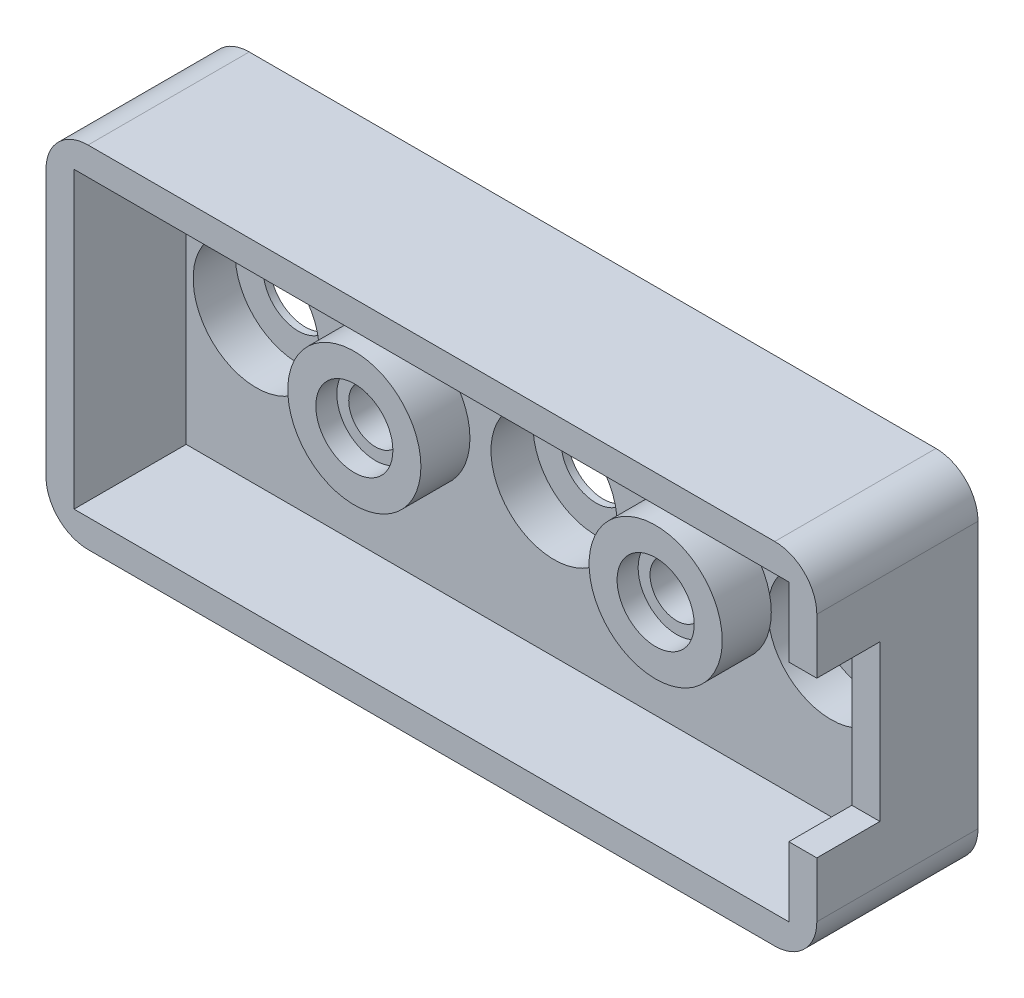
from build123d import *

# Parameters (mm, degrees)
CROQUIS1_W                   = 55
CROQUIS1_H                   = 25
CROQUIS1_R                   = 2.75
SALIENTE_EXTRUIR1_DEPTH      = 2
SALIENTE_EXTRUIR1_DEPTH_BACK = 1.5
CROQUIS2_R                   = 4.75
CROQUIS2_R_2                 = 2.75
SALIENTE_EXTRUIR2_DEPTH      = 3.5
CROQUIS3_W                   = 55
CROQUIS3_H                   = 25
CROQUIS3_W_2                 = 51
CROQUIS3_H_2                 = 21
SALIENTE_EXTRUIR3_DEPTH      = 8
REDONDEO1_R                  = 3
CROQUIS5_W                   = 2
CROQUIS5_H                   = 11.102083366
CORTAR_EXTRUIR1_DEPTH        = 6
CROQUIS8_R                   = 4.5
CORTAR_EXTRUIR4_DEPTH        = 3
CROQUIS11_R                  = 2.75
SALIENTE_EXTRUIR5_DEPTH      = 5.5
CROQUIS12_R                  = 1.9
CORTAR_EXTRUIR11_DEPTH       = 9
CORTAR_EXTRUIR11_DEPTH_BACK  = 4.5
CROQUIS13_R                  = 2.5
CORTAR_EXTRUIR12_DEPTH       = 4.5
CROQUIS14_W                  = 1.5
CROQUIS14_H                  = 11.102083366
SALIENTE_EXTRUIR6_DEPTH      = 2


with BuildPart() as part:
    # Croquis1 → Saliente-Extruir1 (new body, two sides)
    with BuildSketch(Plane.XY) as saliente_extruir1_sk:
        Rectangle(CROQUIS1_W, CROQUIS1_H)
        with Locations((-10, 0)):
            Circle(CROQUIS1_R, mode=Mode.SUBTRACT)
        with Locations((11.5, 0)):
            Circle(CROQUIS1_R, mode=Mode.SUBTRACT)
    extrude(amount=SALIENTE_EXTRUIR1_DEPTH)
    extrude(saliente_extruir1_sk.sketch, amount=-SALIENTE_EXTRUIR1_DEPTH_BACK)

    # Croquis2 → Saliente-Extruir2 (add)
    with BuildSketch(Plane.XY.offset(2)):
        with Locations((-10, 0)):
            Circle(CROQUIS2_R)
        with Locations((-10, 0)):
            Circle(CROQUIS2_R_2, mode=Mode.SUBTRACT)
        with Locations((11.5, 0)):
            Circle(CROQUIS2_R)
        with Locations((11.5, 0)):
            Circle(CROQUIS2_R_2, mode=Mode.SUBTRACT)
    extrude(amount=SALIENTE_EXTRUIR2_DEPTH)

    # Croquis3 → Saliente-Extruir3 (add)
    with BuildSketch(Plane.XY.offset(2)):
        Rectangle(CROQUIS3_W, CROQUIS3_H)
        Rectangle(CROQUIS3_W_2, CROQUIS3_H_2, mode=Mode.SUBTRACT)
    extrude(amount=SALIENTE_EXTRUIR3_DEPTH)

    # Redondeo1
    redondeo1_edges = [part.edges().sort_by_distance(p)[0] for p in [
        (27.5, -12.5, 4.25),
        (-27.5, -12.5, 4.25),
        (-27.5, 12.5, 4.25),
        (27.5, 12.5, 4.25),
    ]]
    fillet(redondeo1_edges, radius=REDONDEO1_R)

    # Croquis5 → Cortar-Extruir1 (cut)
    with BuildSketch(Plane.XY.offset(10)):
        with Locations((26.5, 0)):
            Rectangle(CROQUIS5_W, CROQUIS5_H)
    extrude(amount=-CORTAR_EXTRUIR1_DEPTH, mode=Mode.SUBTRACT)

    # Croquis8 → Cortar-Extruir4 (cut)
    with BuildSketch(Plane.XY.offset(2)):
        with Locations((0.75, 0)):
            Circle(CROQUIS8_R)
        with Locations((-20.5, 0)):
            Circle(CROQUIS8_R)
        with Locations((20.501890269, 0)):
            Circle(CROQUIS8_R)
    extrude(amount=-CORTAR_EXTRUIR4_DEPTH, mode=Mode.SUBTRACT)

    # Croquis11 → Saliente-Extruir5 (add)
    with BuildSketch(Plane(origin=(0, 0, -1.5), x_dir=(-1, 0, 0), z_dir=(0, 0, -1))):
        with Locations((-11.5, 0)):
            Circle(CROQUIS11_R)
        with Locations((10, 0)):
            Circle(CROQUIS11_R)
    extrude(amount=-SALIENTE_EXTRUIR5_DEPTH)

    # Croquis12 → Cortar-Extruir11 (cut, two sides)
    with BuildSketch(Plane.XY.offset(2)) as cortar_extruir11_sk:
        with Locations((-10, 0)):
            Circle(CROQUIS12_R)
        with Locations((11.5, 0)):
            Circle(CROQUIS12_R)
    extrude(amount=CORTAR_EXTRUIR11_DEPTH, mode=Mode.SUBTRACT)
    extrude(cortar_extruir11_sk.sketch, amount=-CORTAR_EXTRUIR11_DEPTH_BACK, mode=Mode.SUBTRACT)

    # Croquis13 → Cortar-Extruir12 (cut, through all)
    with BuildSketch(Plane.XY.offset(2)):
        with Locations((20.501890269, 0)):
            Circle(CROQUIS13_R)
        with Locations((0.75, 0)):
            Circle(CROQUIS13_R)
        with Locations((-20.5, 0)):
            Circle(CROQUIS13_R)
    extrude(amount=-CORTAR_EXTRUIR12_DEPTH, mode=Mode.SUBTRACT)

    # Croquis14 → Saliente-Extruir6 (add)
    with BuildSketch(Plane(origin=(27.5, 0, 0), x_dir=(0, 0, -1), z_dir=(1, 0, 0))):
        with Locations((-4.75, 0)):
            Rectangle(CROQUIS14_W, CROQUIS14_H)
    extrude(amount=-SALIENTE_EXTRUIR6_DEPTH)


solid = part.part
